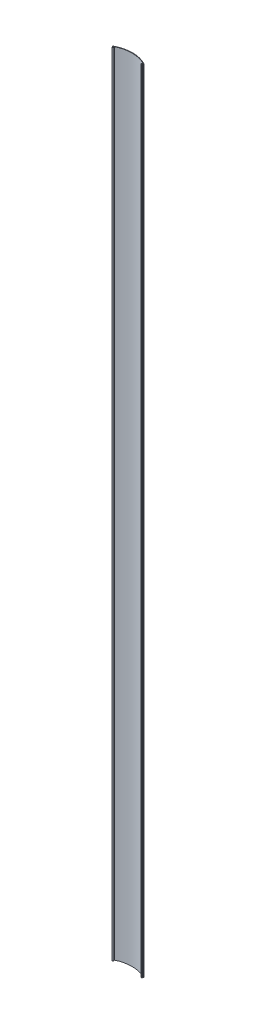
from build123d import *

# Parameters (mm, degrees)
BOSS_EXTRUDE1_DEPTH = 2590.8
CUT_EXTRUDE1_DEPTH  = 2591.8
BOSS_EXTRUDE2_DEPTH = 2590.8
FILLET1_R           = 0.508


with BuildPart() as part:
    # Sketch1 → Boss-Extrude1 (new body)
    with BuildSketch(Plane(origin=(0, 0, 0), x_dir=(1, 0, 0), z_dir=(0, 1, 0))):
        with BuildLine():
            Line((101.58476, 5.338063609), (101.58476, 6.354063609))
            ThreePointArc((101.58476, 6.354063609), (50.79238, 19.05), (0, 6.354063609))
            Line((0, 6.354063609), (0, 5.338063609))
            Line((0, 5.338063609), (1.338554634, 5.338063609))
            ThreePointArc((1.338554634, 5.338063609), (45.188812602, 17.378377427), (90.062082389, 10.016044959))
            ThreePointArc((90.062082389, 10.016044959), (91.218156641, 9.549225792), (92.368682931, 9.068895628))
            ThreePointArc((92.368682931, 9.068895628), (96.251044015, 7.328911154), (100.06076, 5.435148318))
            Line((100.06076, 5.435148318), (100.06076, 4.322063609))
            ThreePointArc((100.06076, 4.322063609), (100.209549755, 3.962853364), (100.56876, 3.814063609))
            Line((100.56876, 3.814063609), (100.82276, 3.814063609))
            Line((100.82276, 3.814063609), (101.58476, 5.338063609))
        make_face()
    extrude(amount=BOSS_EXTRUDE1_DEPTH)

    # Sketch3 → Cut-Extrude1 (cut, through all)
    with BuildSketch(Plane(origin=(0, 2590.8, 0), x_dir=(1, 0, 0), z_dir=(0, 1, 0))):
        Polygon((100.06076, 2.923708758), (101.58476, 2.923708758), (101.58476, 5.592063609), (100.06076, 5.435148318), align=None)
        Polygon((0, 5.592063609), (0.4067845, 4.474432381), (0, 4.474432381), align=None)
    extrude(amount=-CUT_EXTRUDE1_DEPTH, mode=Mode.SUBTRACT)

    # Sketch2 → Boss-Extrude2 (add)
    with BuildSketch(Plane(origin=(0, 2590.8, 0), x_dir=(1, 0, 0), z_dir=(0, 1, 0))):
        with BuildLine():
            Line((101.238078351, 4.639563606), (101.58476, 5.592063609))
            Line((101.58476, 5.592063609), (97.711183428, 6.625490634))
            ThreePointArc((97.711183428, 6.625490634), (97.924124129, 6.275131553), (97.695976798, 5.934479203))
            ThreePointArc((97.695976798, 5.934479203), (96.254692814, 2.421137976), (99.718733273, 0.865088556))
            ThreePointArc((99.718733273, 0.865088556), (99.858345852, 0.953692868), (99.947271519, 1.093100982))
            Line((99.947271519, 1.093100982), (100.173716674, 1.715253931))
            ThreePointArc((100.173716674, 1.715253931), (100.127790714, 2.064096228), (99.815693785, 2.226563606))
            Line((99.815693785, 2.226563606), (98.79076, 2.226563606))
            ThreePointArc((98.79076, 2.226563606), (97.58426, 3.433063606), (98.79076, 4.639563606))
            Line((98.79076, 4.639563606), (101.238078351, 4.639563606))
        make_face()
        with BuildLine():
            ThreePointArc((1.769066215, 2.226563606), (1.456969286, 2.064096228), (1.411043326, 1.715253931))
            Line((1.411043326, 1.715253931), (1.637488481, 1.093100982))
            ThreePointArc((1.637488481, 1.093100982), (1.726414148, 0.953692868), (1.866026727, 0.865088556))
            ThreePointArc((1.866026727, 0.865088556), (5.330067186, 2.421137976), (3.888783202, 5.934479203))
            ThreePointArc((3.888783202, 5.934479203), (3.660635871, 6.275131553), (3.873576572, 6.625490634))
            Line((3.873576572, 6.625490634), (0, 5.592063609))
            Line((0, 5.592063609), (0.346681649, 4.639563606))
            Line((0.346681649, 4.639563606), (2.794, 4.639563606))
            ThreePointArc((2.794, 4.639563606), (4.0005, 3.433063606), (2.794, 2.226563606))
            Line((2.794, 2.226563606), (1.769066215, 2.226563606))
        make_face()
    extrude(amount=-BOSS_EXTRUDE2_DEPTH)

    # Fillet1
    fillet1_edges = [part.edges().sort_by_distance(p)[0] for p in [
        (101.238078351, 1295.4, -4.639563606),
        (0.346681649, 1295.4, -4.639563606),
    ]]
    fillet(fillet1_edges, radius=FILLET1_R)


solid = part.part
